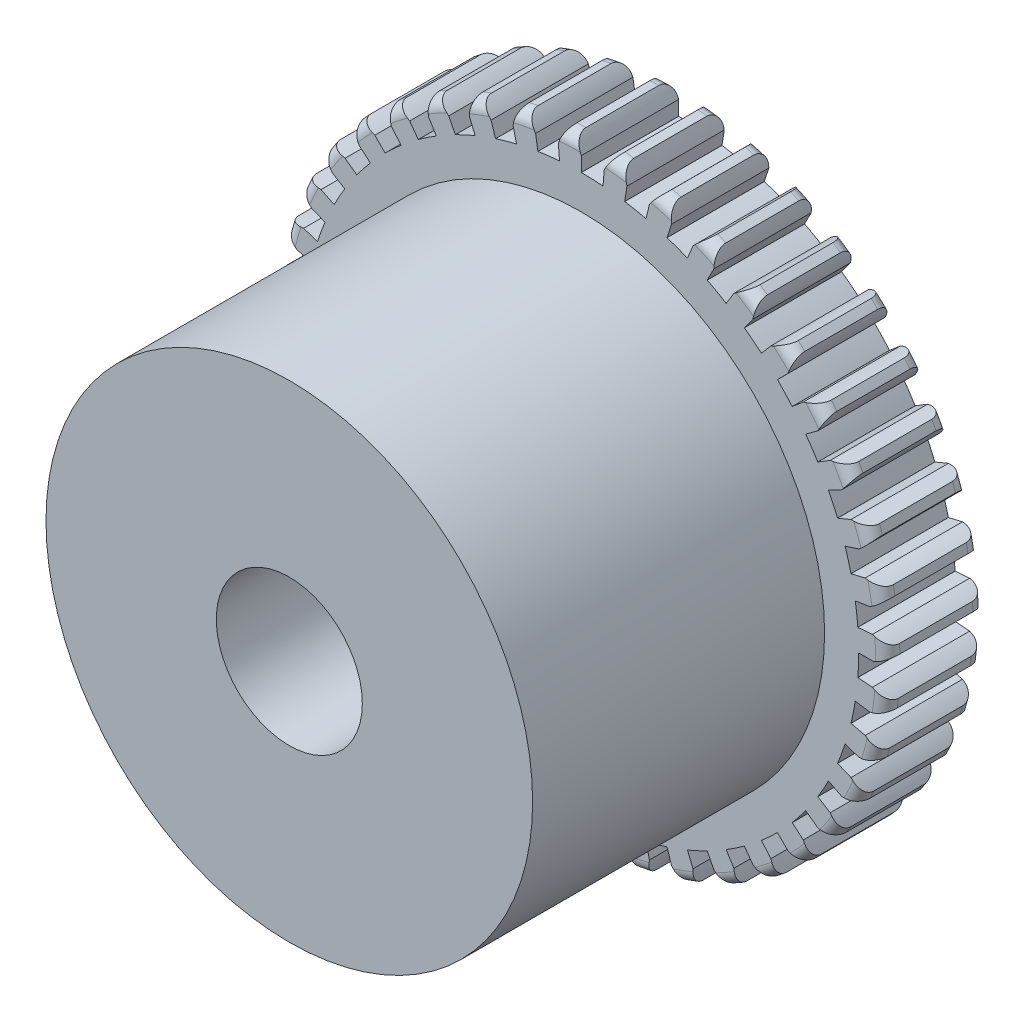
from build123d import *

# Parameters (mm, degrees)
OUTER_PROFILE_R      = 6.3
MAIN_WHEEL_DEPTH     = 1
TOOTH_CUT_DEPTH      = 2
CIRPATTERN1_COUNT    = 40
SKETCH5_R            = 5
EXTENDED_MOUNT_DEPTH = 6
SKETCH6_R            = 1.5
SHAFT_DEPTH          = 1
SHAFT_DEPTH_BACK     = 9.0000001


with BuildPart() as part:
    # Outer_Profile → Main_Wheel (new body, symmetric)
    with BuildSketch(Plane.XY):
        Circle(OUTER_PROFILE_R)
    extrude(amount=MAIN_WHEEL_DEPTH, both=True)

    # Tooth_Profile → Tooth_Cut (cut, symmetric)
    with BuildSketch(Plane.XY):
        with BuildLine():
            Line((0, 5.999814303), (0, 5.700999912))
            ThreePointArc((0, 5.700999912), (0.000292831, 5.700292868), (0.000999825, 5.699999912))
            ThreePointArc((0.000999825, 5.699999912), (0.22378095, 5.695605507), (0.446220096, 5.68250716))
            ThreePointArc((0.446220096, 5.68250716), (0.446947895, 5.682743742), (0.447295298, 5.683425632))
            Line((0.447295298, 5.683425632), (0.470740005, 5.981318878))
            ThreePointArc((0.470740005, 5.981318878), (0.596525398, 6.196715783), (0.756069102, 6.387995589))
            Line((0.756069102, 6.387995589), (0.81351584, 6.87336063))
            Line((0.81351584, 6.87336063), (-0.271730383, 6.91600007))
            Line((-0.271730383, 6.91600007), (-0.252542036, 6.427624028))
            ThreePointArc((-0.252542036, 6.427624028), (-0.108497792, 6.22441622), (0, 5.999814303))
        make_face()
    tooth_cut = extrude(amount=TOOTH_CUT_DEPTH, both=True, mode=Mode.SUBTRACT)

    # CirPattern1: Tooth_Cut ×40 about axis
    cirpattern1_axis = Axis((0, 0, 0), (0, 0, 1))
    for i in range(1, CIRPATTERN1_COUNT):
        add(tooth_cut.rotate(cirpattern1_axis, i * 360 / CIRPATTERN1_COUNT), mode=Mode.SUBTRACT)

    # Sketch4 → Gear_tooth_fillets (revolve, cut)
    with BuildSketch(Plane(origin=(0, 0, 0), x_dir=(1, 0, 0), z_dir=(0, 1, 0))):
        with BuildLine():
            Line((-6.3, 0), (-6.3, 0.75))
            ThreePointArc((-6.3, 0.75), (-6.226776695, 0.926776695), (-6.05, 1))
            Line((-6.05, 1), (-3.426948071, 1))
            Line((-3.426948071, 1), (-3.426948071, 3.211361584))
            Line((-3.426948071, 3.211361584), (-9.247031488, 3.211361584))
            Line((-9.247031488, 3.211361584), (-9.247031488, -3.211361584))
            Line((-9.247031488, -3.211361584), (-3.426948071, -3.211361584))
            Line((-3.426948071, -3.211361584), (-3.426948071, -1))
            Line((-3.426948071, -1), (-6.05, -1))
            ThreePointArc((-6.05, -1), (-6.226776695, -0.926776695), (-6.3, -0.75))
            Line((-6.3, -0.75), (-6.3, 0))
        make_face()
    revolve(axis=Axis((0, 0, -2.2), (0, 0, 1)), mode=Mode.SUBTRACT)

    # Sketch5 → Extended_Mount (add)
    with BuildSketch(Plane.XY.offset(1)):
        Circle(SKETCH5_R)
    extrude(amount=EXTENDED_MOUNT_DEPTH)

    # Sketch6 → Shaft (cut, two sides)
    with BuildSketch(Plane.XY.offset(7)) as shaft_sk:
        Circle(SKETCH6_R)
    extrude(amount=SHAFT_DEPTH, mode=Mode.SUBTRACT)
    extrude(shaft_sk.sketch, amount=-SHAFT_DEPTH_BACK, mode=Mode.SUBTRACT)


solid = part.part
